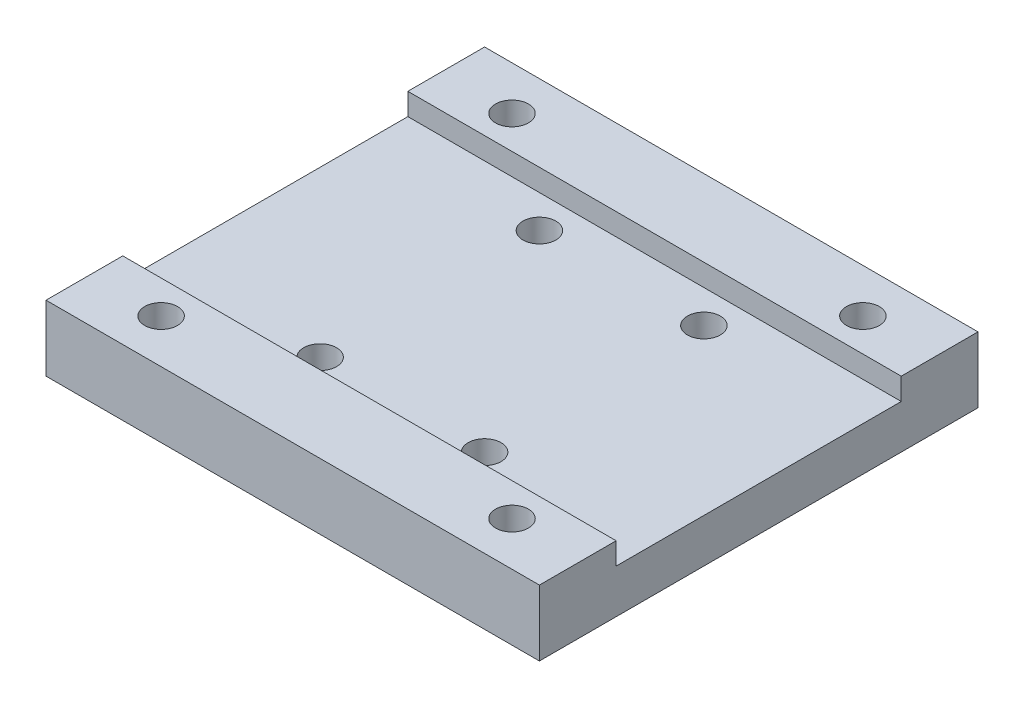
from build123d import *

# Parameters (mm, degrees)
SKETCH_2_W                = 45
SKETCH_2_H                = 33
SKETCH_2_R                = 1.5
EXTRUDE_1_DEPTH           = 6
SKETCH_3_W                = 45
SKETCH_3_H                = 3.5
EXTRUDE_2_DEPTH           = 6
SKETCH_20_W               = 45
SKETCH_20_H               = 27.5
CUT_EXTRUDE_5_DEPTH       = 2
EXTRUDE_START             = -2
SKETCH_21_W               = 45
SKETCH_21_H               = 3.5
EXTRUDE_3_DEPTH           = 2
HOLE_WIZARD_3_0_3_1_D     = 3
HOLE_WIZARD_3_0_3_1_DEPTH = 6
HOLE_WIZARD_M3_2_D        = 2.5
HOLE_WIZARD_M3_2_DEPTH    = 4
HOLE_WIZARD_M3_2_TIP      = 0.751075774
HOLE_WIZARD_1_D           = 3
HOLE_WIZARD_1_DEPTH       = 6
HOLE_WIZARD_1_CBORE_D     = 6
HOLE_WIZARD_1_CBORE_DEPTH = 3


with BuildPart() as part:
    # 草图2 → 凸台-拉伸1 (new body)
    with BuildSketch(Plane(origin=(0, 0, 0), x_dir=(1, 0, 0), z_dir=(0, 1, 0))):
        Rectangle(SKETCH_2_W, SKETCH_2_H)
        with Locations((-7.5, 10)):
            Circle(SKETCH_2_R, mode=Mode.SUBTRACT)
        with Locations((7.5, 10)):
            Circle(SKETCH_2_R, mode=Mode.SUBTRACT)
        with Locations((-7.5, -10)):
            Circle(SKETCH_2_R, mode=Mode.SUBTRACT)
        with Locations((7.5, -10)):
            Circle(SKETCH_2_R, mode=Mode.SUBTRACT)
    extrude(amount=EXTRUDE_1_DEPTH)

    # 草图3 → 凸台-拉伸2 (add)
    with BuildSketch(Plane.XZ):
        with Locations((0, -18.25)):
            Rectangle(SKETCH_3_W, SKETCH_3_H)
        with Locations((0, 18.25)):
            Rectangle(SKETCH_3_W, SKETCH_3_H)
    extrude(amount=-EXTRUDE_2_DEPTH)

    # 草图20 → 切除-拉伸5 (cut)
    with BuildSketch(Plane(origin=(0, 6, 0), x_dir=(1, 0, 0), z_dir=(0, 1, 0))):
        Rectangle(SKETCH_20_W, SKETCH_20_H)
    extrude(amount=-CUT_EXTRUDE_5_DEPTH, mode=Mode.SUBTRACT)

    # 草图21 → 凸台-拉伸3 (add)
    with BuildSketch(Plane.XZ.offset(-4).offset(EXTRUDE_START)):
        with Locations((0, -14.75)):
            Rectangle(SKETCH_21_W, SKETCH_21_H)
        with Locations((0, 14.75)):
            Rectangle(SKETCH_21_W, SKETCH_21_H)
    extrude(amount=EXTRUDE_3_DEPTH)

    # Ø3.0 (3) 直径孔1
    with Locations(Plane(origin=(0, 6, 0), x_dir=(1, 0, 0), z_dir=(0, 1, 0))):
        with Locations((-16, 16), (16, 16), (16, -16), (-16, -16)):
            Hole(HOLE_WIZARD_3_0_3_1_D / 2, depth=HOLE_WIZARD_3_0_3_1_DEPTH)

    # M3 螺纹孔2
    with Locations(Plane(origin=(0, 0, 0), x_dir=(-1, 0, 0), z_dir=(0, -1, 0))):
        with Locations((3.5, -17), (-3.5, -17), (-3.5, 17), (3.5, 17)):
            Hole(HOLE_WIZARD_M3_2_D / 2, depth=HOLE_WIZARD_M3_2_DEPTH)
            with Locations((0, 0, -(HOLE_WIZARD_M3_2_DEPTH + HOLE_WIZARD_M3_2_TIP / 2))):  # 118° drill point
                Cone(0, HOLE_WIZARD_M3_2_D / 2, HOLE_WIZARD_M3_2_TIP, mode=Mode.SUBTRACT)

    # 打孔尺寸(%根据)内六角圆柱头螺钉的类型1
    with Locations(Plane(origin=(0, 0, 0), x_dir=(-1, 0, 0), z_dir=(0, -1, 0))):
        with Locations((-16, 16), (16, 16), (16, -16), (-16, -16)):
            CounterBoreHole(HOLE_WIZARD_1_D / 2, HOLE_WIZARD_1_CBORE_D / 2, HOLE_WIZARD_1_CBORE_DEPTH, depth=HOLE_WIZARD_1_DEPTH)


solid = part.part
